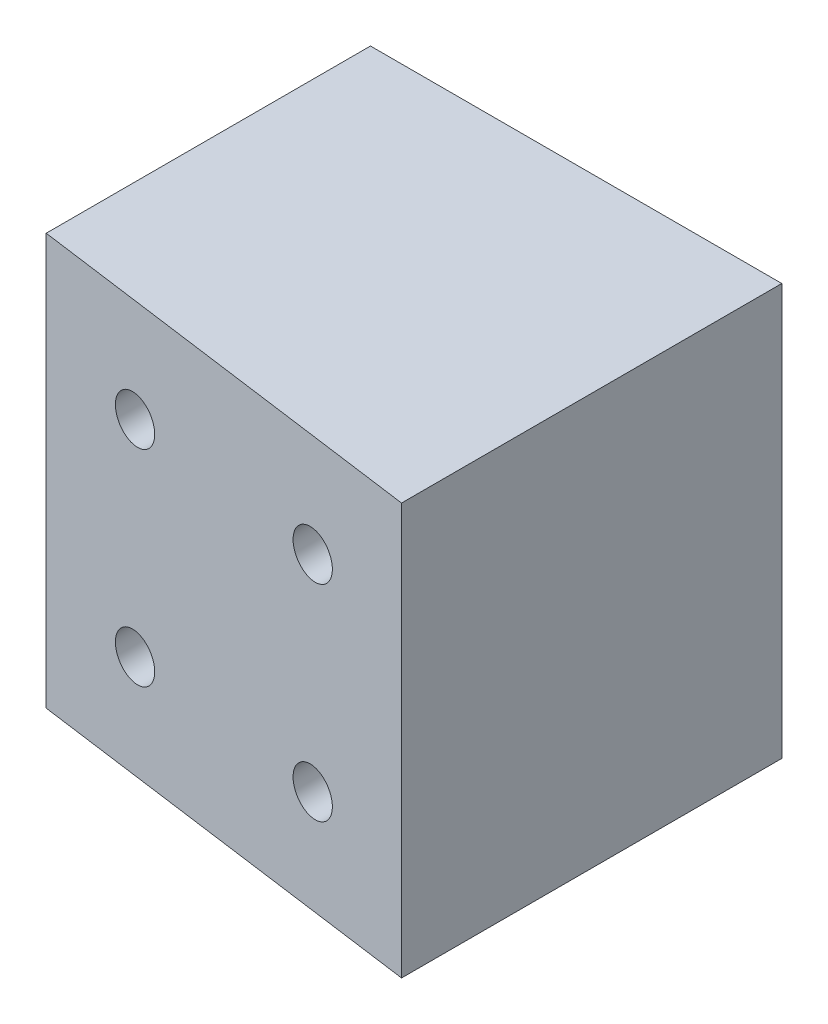
from build123d import *

# Parameters (mm, degrees)
BOSS_EXTRUDE1_DEPTH                                = 50.8
CSK_FOR_10_FLAT_HEAD_MACHINE_SCREW_100_D           = 5.6134
CSK_FOR_10_FLAT_HEAD_MACHINE_SCREW_100_CSINK_D     = 17.78
CSK_FOR_10_FLAT_HEAD_MACHINE_SCREW_100_CSINK_ANGLE = 90
CSK_FOR_10_FLAT_HEAD_MACHINE_SCREW_2_D             = 5.6134
CSK_FOR_10_FLAT_HEAD_MACHINE_SCREW_2_CSINK_D       = 17.78
CSK_FOR_10_FLAT_HEAD_MACHINE_SCREW_2_CSINK_ANGLE   = 90


with BuildPart() as part:
    # Sketch1 → Boss-Extrude1 (new body)
    with BuildSketch(Plane(origin=(0, 0, 0), x_dir=(1, 0, 0), z_dir=(0, 1, 0))):
        Polygon((0, 0), (-50.8, 0), (-50.8, -40.046314449), (0, -46.961736623), align=None)
    extrude(amount=BOSS_EXTRUDE1_DEPTH)

    # CSK for _10 Flat Head Machine Screw _100 (through all)
    with Locations(Plane(origin=(295.341972913, -214.795089466, 50.8), x_dir=(-1, 0, 0), z_dir=(0, 0, 1))):
        with Locations((333.441972913, -227.495089466), (333.441972913, -252.895089466), (333.441972913, -329.095089466), (333.441972913, -354.495089466)):
            CounterSinkHole(CSK_FOR_10_FLAT_HEAD_MACHINE_SCREW_100_D / 2, CSK_FOR_10_FLAT_HEAD_MACHINE_SCREW_100_CSINK_D / 2, counter_sink_angle=CSK_FOR_10_FLAT_HEAD_MACHINE_SCREW_100_CSINK_ANGLE)

    # CSK for _10 Flat Head Machine Screw  2 (through all)
    with Locations(Plane(origin=(295.341972913, -316.395089466, 53.34), x_dir=(-1, 0, 0), z_dir=(0, 0, 1))):
        with Locations((308.041972913, -252.895089466), (308.041972913, -227.495089466), (308.041972913, -329.095089466), (308.041972913, -354.495089466)):
            CounterSinkHole(CSK_FOR_10_FLAT_HEAD_MACHINE_SCREW_2_D / 2, CSK_FOR_10_FLAT_HEAD_MACHINE_SCREW_2_CSINK_D / 2, counter_sink_angle=CSK_FOR_10_FLAT_HEAD_MACHINE_SCREW_2_CSINK_ANGLE)


solid = part.part
